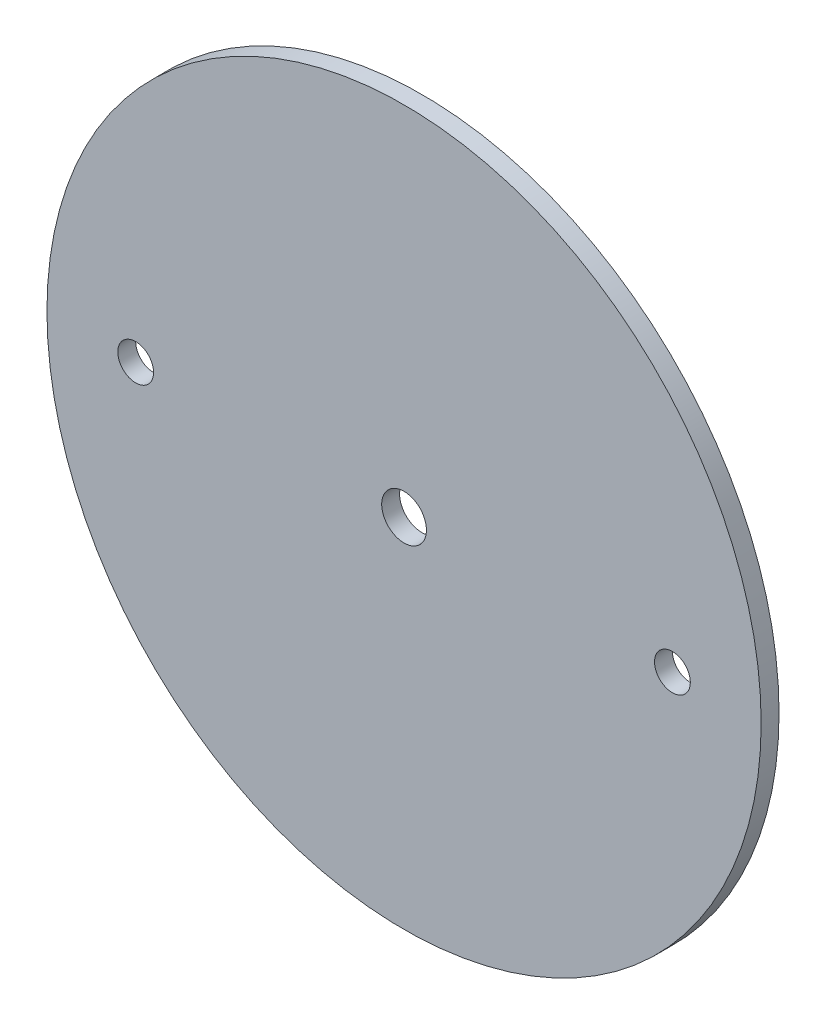
from build123d import *

# Parameters (mm, degrees)
SKETCH1_R                          = 63.373
BOSS_EXTRUDE1_DEPTH                = 1.5875
F_1_4_0_25_DIAMETER_HOLE1_D        = 6.35
F_5_16_0_3125_DIAMETER_HOLE1_D     = 7.9375
F_5_16_0_3125_DIAMETER_HOLE1_DEPTH = 3.302


with BuildPart() as part:
    # Sketch1 → Boss-Extrude1 (new body, symmetric)
    with BuildSketch(Plane.XY):
        Circle(SKETCH1_R)
    extrude(amount=BOSS_EXTRUDE1_DEPTH, both=True)

    # 1/4 (0.25) Diameter Hole1 (through all)
    with Locations(Plane.XY.offset(1.5875)):
        with Locations((-47.625, 0), (47.625, 0)):
            Hole(F_1_4_0_25_DIAMETER_HOLE1_D / 2)

    # 5/16 (0.3125) Diameter Hole1
    with Locations(Plane.XY.offset(1.5875)):
        with Locations((0, 0)):
            Hole(F_5_16_0_3125_DIAMETER_HOLE1_D / 2, depth=F_5_16_0_3125_DIAMETER_HOLE1_DEPTH)


solid = part.part
